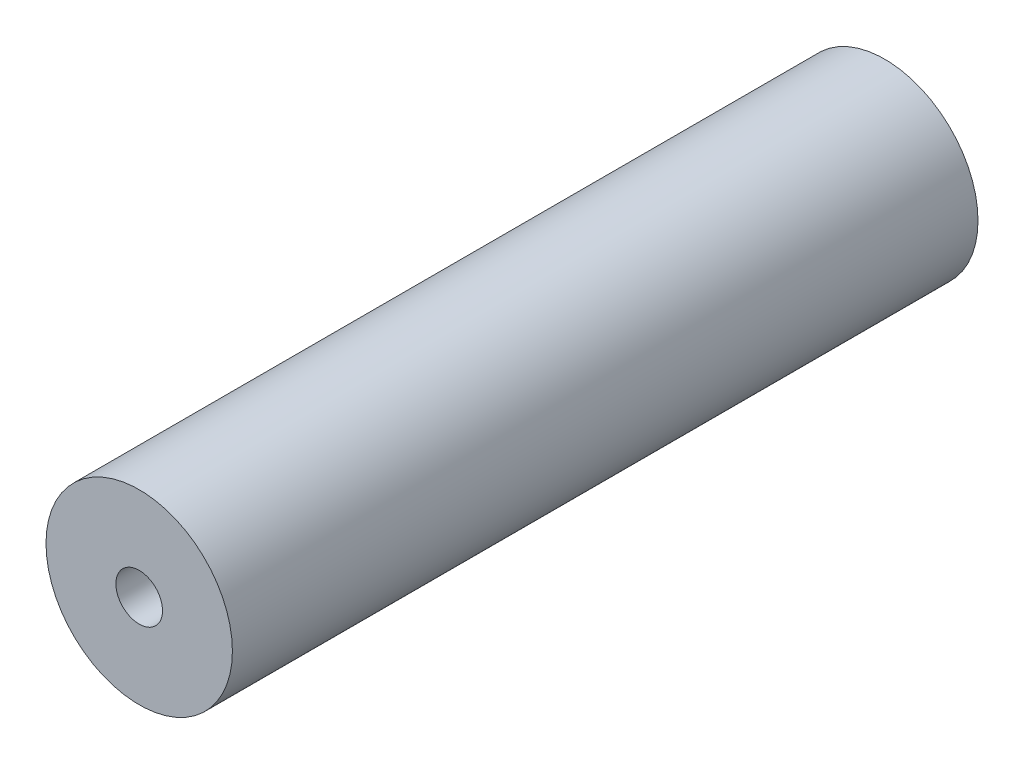
from build123d import *

# Parameters (mm, degrees)
SKETCH1_R           = 38.1
SKETCH1_R_2         = 9.525
BOSS_EXTRUDE1_DEPTH = 304.8


with BuildPart() as part:
    # Sketch1 → Boss-Extrude1 (new body)
    with BuildSketch(Plane.XY):
        Circle(SKETCH1_R)
        Circle(SKETCH1_R_2, mode=Mode.SUBTRACT)
    extrude(amount=BOSS_EXTRUDE1_DEPTH)


solid = part.part
